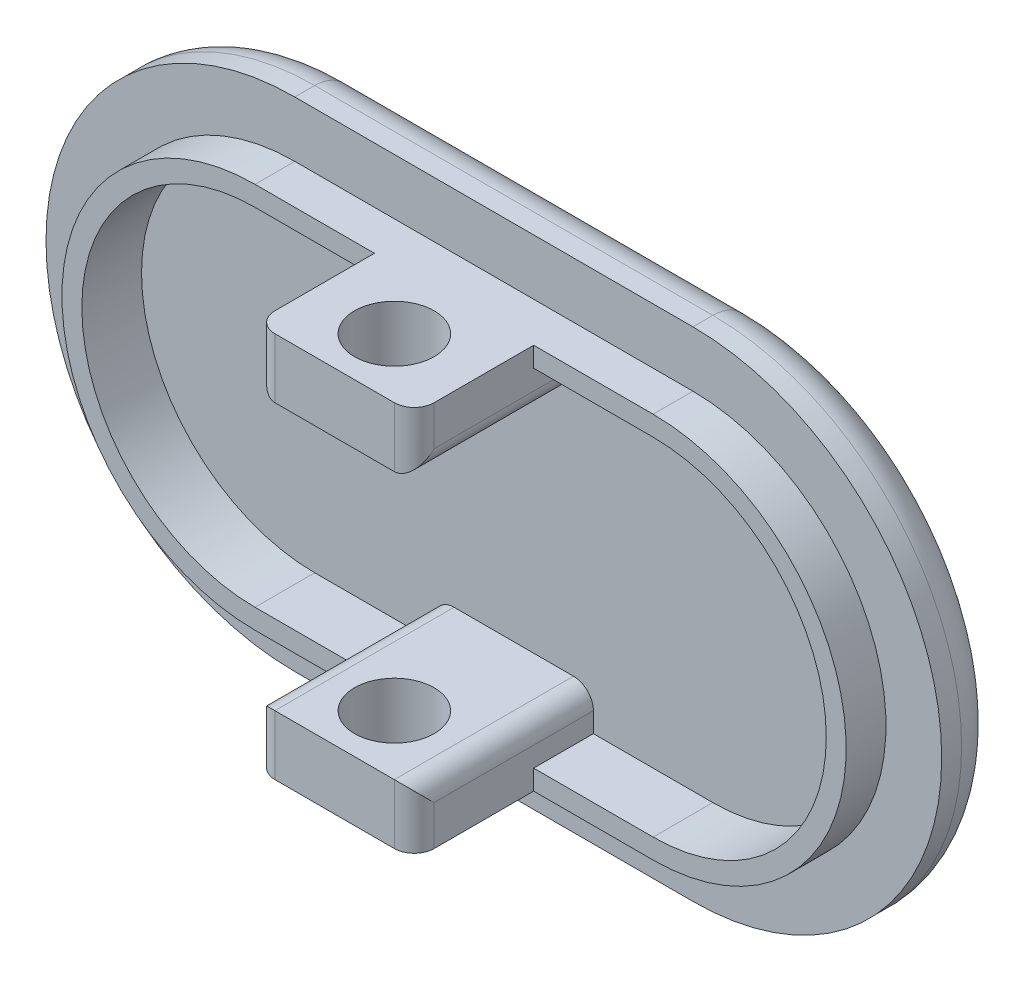
from build123d import *

# Parameters (mm, degrees)
RESSALTO_EXTRUS_O1_DEPTH = 3
RESSALTO_EXTRUS_O2_DEPTH = 11
CORTE_EXTRUS_O1_DEPTH    = 6
ESBO_O3_R                = 2
CORTE_EXTRUS_O2_DEPTH    = 23.2
FILETE1_R                = 1
FILETE2_R                = 2
CORTE_EXTRUS_O3_DEPTH    = 3


with BuildPart() as part:
    # Esboço1 → Ressalto-extrusão1 (new body)
    with BuildSketch(Plane.XY):
        with BuildLine():
            Line((-10, 12.5), (10, 12.5))
            ThreePointArc((10, 12.5), (22.5, 0), (10, -12.5))
            Line((10, -12.5), (-10, -12.5))
            ThreePointArc((-10, -12.5), (-22.5, 0), (-10, 12.5))
        make_face()
        with BuildLine():
            Line((-10, 9.7), (10, 9.7))
            ThreePointArc((10, 9.7), (19.7, 0), (10, -9.7))
            Line((10, -9.7), (-10, -9.7))
            ThreePointArc((-10, -9.7), (-19.7, 0), (-10, 9.7))
        make_face(mode=Mode.SUBTRACT)
    extrude(amount=RESSALTO_EXTRUS_O1_DEPTH)

    # Esboço1<2> → Ressalto-extrusão2 (add)
    with BuildSketch(Plane.XY):
        with BuildLine():
            Line((-10, 9.7), (10, 9.7))
            ThreePointArc((10, 9.7), (19.7, 0), (10, -9.7))
            Line((10, -9.7), (-10, -9.7))
            ThreePointArc((-10, -9.7), (-19.7, 0), (-10, 9.7))
        make_face()
    extrude(amount=RESSALTO_EXTRUS_O2_DEPTH)

    # Esboço2 → Corte-extrusão1 (cut)
    with BuildSketch(Plane.XY.offset(11)):
        with BuildLine():
            Line((-10, -9.7), (-4, -9.7))
            Line((-4, -9.7), (-4, -6.7))
            Line((-4, -6.7), (4, -6.7))
            Line((4, -6.7), (4, -9.7))
            Line((4, -9.7), (10, -9.7))
            ThreePointArc((10, -9.7), (19.7, 0), (10, 9.7))
            Line((10, 9.7), (4, 9.7))
            Line((4, 9.7), (4, 6.7))
            Line((4, 6.7), (-4, 6.7))
            Line((-4, 6.7), (-4, 9.7))
            Line((-4, 9.7), (-10, 9.7))
            ThreePointArc((-10, 9.7), (-19.7, 0), (-10, -9.7))
        make_face()
    extrude(amount=-CORTE_EXTRUS_O1_DEPTH, mode=Mode.SUBTRACT)

    # Esboço3 → Corte-extrusão2 (cut, through all)
    with BuildSketch(Plane.XZ.offset(9.7)):
        with Locations((0, 8)):
            Circle(ESBO_O3_R)
    extrude(amount=-CORTE_EXTRUS_O2_DEPTH, mode=Mode.SUBTRACT)

    # Filete1
    filete1_edges = [part.edges().sort_by_distance(p)[0] for p in [
        (-4, 6.7, 8),
        (4, 6.7, 8),
        (4, -6.7, 8),
        (-4, -6.7, 8),
        (-4, -8.2, 11),
        (4, -8.2, 11),
        (4, 8.2, 11),
        (-4, 8.2, 11),
    ]]
    fillet(filete1_edges, radius=FILETE1_R)

    # Filete2
    filete2_edges = [part.edges().sort_by_distance(p)[0] for p in [
        (0, 12.5, 0),
        (22.5, 0, 0),
        (0, -12.5, 0),
        (-22.5, 0, 0),
    ]]
    fillet(filete2_edges, radius=FILETE2_R)

    # Esboço4 → Corte-extrusão3 (cut)
    with BuildSketch(Plane.XY.offset(5)):
        with BuildLine():
            Line((-10, -8.7), (-4, -8.7))
            Line((-4, -8.7), (-4, -7.7))
            ThreePointArc((-4, -7.7), (-3.707106781, -6.992893219), (-3, -6.7))
            Line((-3, -6.7), (3, -6.7))
            ThreePointArc((3, -6.7), (3.707106781, -6.992893219), (4, -7.7))
            Line((4, -7.7), (4, -8.7))
            Line((4, -8.7), (10, -8.7))
            ThreePointArc((10, -8.7), (18.7, 0), (10, 8.7))
            Line((10, 8.7), (4, 8.7))
            Line((4, 8.7), (4, 7.7))
            ThreePointArc((4, 7.7), (3.707106781, 6.992893219), (3, 6.7))
            Line((3, 6.7), (-3, 6.7))
            ThreePointArc((-3, 6.7), (-3.707106781, 6.992893219), (-4, 7.7))
            Line((-4, 7.7), (-4, 8.7))
            Line((-4, 8.7), (-10, 8.7))
            ThreePointArc((-10, 8.7), (-18.7, 0), (-10, -8.7))
        make_face()
    extrude(amount=-CORTE_EXTRUS_O3_DEPTH, mode=Mode.SUBTRACT)


solid = part.part
